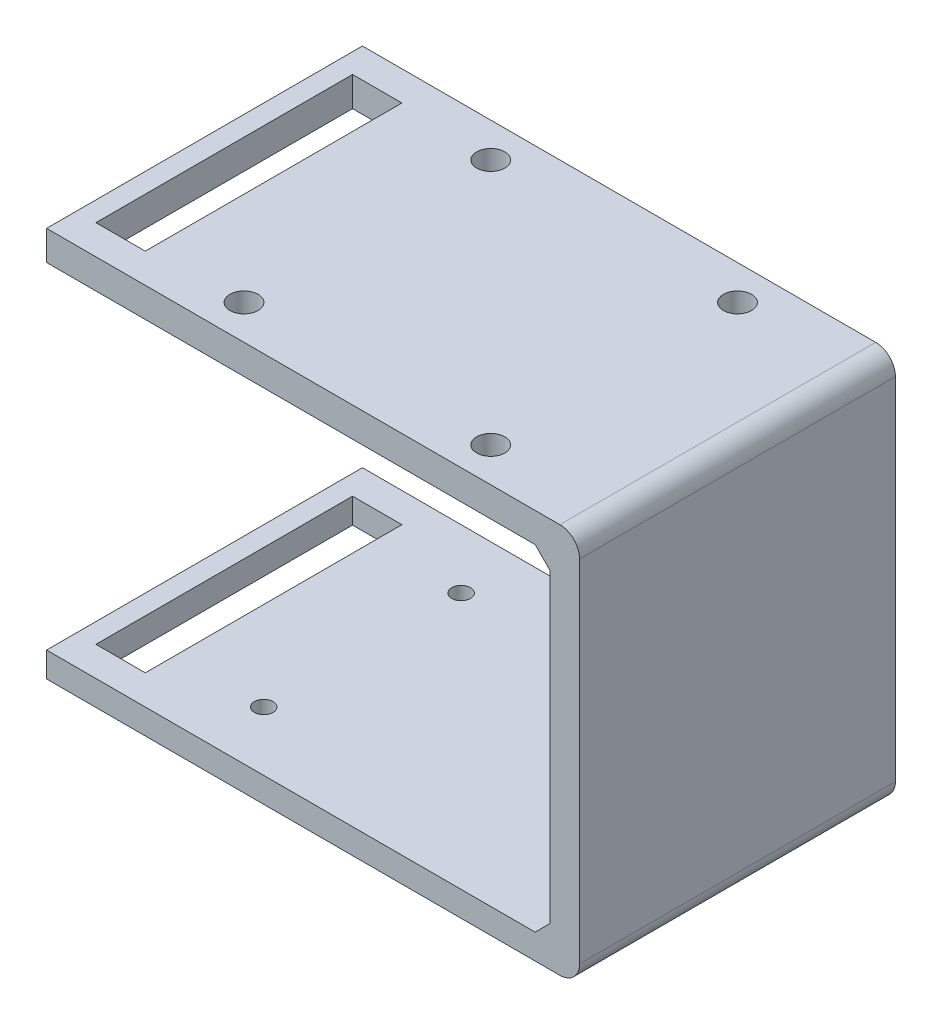
from build123d import *

# Parameters (mm, degrees)
SKETCH1_W               = 54
SKETCH1_H               = 32
SKETCH1_R               = 0.95
BOSS_EXTRUDE1_DEPTH     = 2.54
SKETCH3_W               = 3
SKETCH3_H               = 32
BOSS_EXTRUDE2_DEPTH     = 37
SKETCH4_W               = 32
SKETCH4_H               = 3
BOSS_EXTRUDE3_DEPTH     = 47
FILLET1_R               = 2
SKETCH5_R               = 1.425
CUT_EXTRUDE1_DEPTH      = 20
SKETCH8_W               = 32
SKETCH8_H               = 3
BOSS_EXTRUDE4_DEPTH     = 4
SKETCH7_W               = 5
SKETCH7_H               = 26
CUT_EXTRUDE3_DEPTH      = 1
CUT_EXTRUDE3_DEPTH_BACK = 40.54
CHAMFER1_SIZE           = 1.5


with BuildPart() as part:
    # Sketch1 → Boss-Extrude1 (new body)
    with BuildSketch(Plane(origin=(0, 0, 0), x_dir=(1, 0, 0), z_dir=(0, 1, 0))):
        with Locations((1, -10)):
            Rectangle(SKETCH1_W, SKETCH1_H)
        with Locations((-10, 0)):
            Circle(SKETCH1_R, mode=Mode.SUBTRACT)
        with Locations((20, -10)):
            Circle(SKETCH1_R, mode=Mode.SUBTRACT)
        with Locations((-10, -20)):
            Circle(SKETCH1_R, mode=Mode.SUBTRACT)
    extrude(amount=BOSS_EXTRUDE1_DEPTH)

    # Sketch3 → Boss-Extrude2 (add)
    with BuildSketch(Plane(origin=(0, 2.54, 0), x_dir=(1, 0, 0), z_dir=(0, 1, 0))):
        with Locations((26.5, -10)):
            Rectangle(SKETCH3_W, SKETCH3_H)
    extrude(amount=BOSS_EXTRUDE2_DEPTH)

    # Sketch4 → Boss-Extrude3 (add)
    with BuildSketch(Plane.ZY.offset(-25)):
        with Locations((10, 38.04)):
            Rectangle(SKETCH4_W, SKETCH4_H)
    extrude(amount=BOSS_EXTRUDE3_DEPTH)

    # Fillet1
    fillet1_edges = [part.edges().sort_by_distance(p)[0] for p in [
        (28, 0, 10),
        (28, 39.54, 10),
    ]]
    fillet(fillet1_edges, radius=FILLET1_R)

    # Sketch5 → Cut-Extrude1 (cut)
    with BuildSketch(Plane(origin=(0, 39.54, 0), x_dir=(1, 0, 0), z_dir=(0, 1, 0))):
        with Locations((-9.5, 2.5)):
            Circle(SKETCH5_R)
        with Locations((15.5, 2.5)):
            Circle(SKETCH5_R)
        with Locations((15.5, -22.5)):
            Circle(SKETCH5_R)
        with Locations((-9.5, -22.5)):
            Circle(SKETCH5_R)
    extrude(amount=-CUT_EXTRUDE1_DEPTH, mode=Mode.SUBTRACT)

    # Sketch8 → Boss-Extrude4 (add)
    with BuildSketch(Plane.ZY.offset(22)):
        with Locations((10, 38.04)):
            Rectangle(SKETCH8_W, SKETCH8_H)
    extrude(amount=BOSS_EXTRUDE4_DEPTH)

    # Sketch7 → Cut-Extrude3 (cut, two sides)
    with BuildSketch(Plane(origin=(0, 39.54, 0), x_dir=(1, 0, 0), z_dir=(0, 1, 0))) as cut_extrude3_sk:
        with Locations((-21.5, -10)):
            Rectangle(SKETCH7_W, SKETCH7_H)
    extrude(amount=CUT_EXTRUDE3_DEPTH, mode=Mode.SUBTRACT)
    extrude(cut_extrude3_sk.sketch, amount=-CUT_EXTRUDE3_DEPTH_BACK, mode=Mode.SUBTRACT)

    # Chamfer1
    chamfer1_edges = [part.edges().sort_by_distance(p)[0] for p in [
        (25, 2.54, 10),
        (25, 36.54, 10),
    ]]
    chamfer(chamfer1_edges, length=CHAMFER1_SIZE)


solid = part.part
